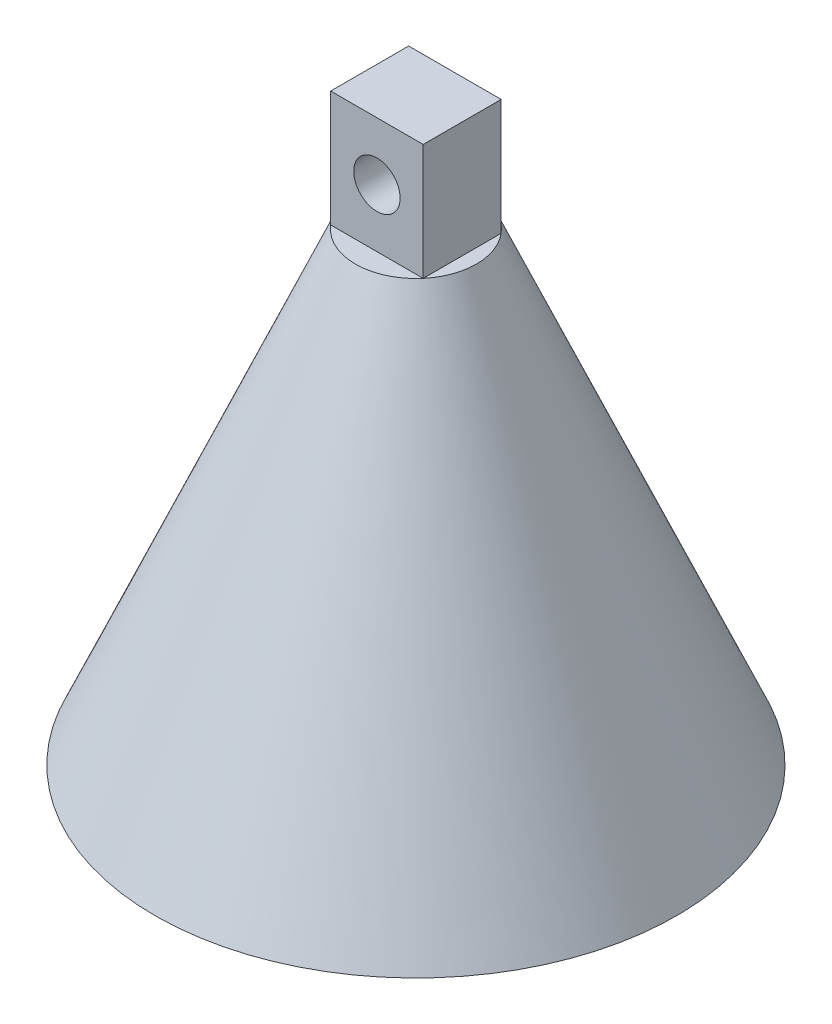
from build123d import *

# Parameters (mm, degrees)
ESQUISSE2_W                  = 7.975229024
ESQUISSE2_H                  = 6.721241558
BOSS_EXTRU_1_DEPTH           = 10
ENL_V_MAT_EXTRU_1_DEPTH      = 14
ENL_V_MAT_EXTRU_1_DEPTH_BACK = 13


with BuildPart() as part:
    # Esquisse1 → Révolution1 (revolve)
    with BuildSketch(Plane.XY):
        Polygon((17.285132647, 40), (19.285132647, 40), (2, 0), (0, 0), align=None)
        Polygon((19.285132647, 40), (18.145144725, 37.361922653), (22.5, 37.361922653), (22.5, 40), align=None)
    revolve(axis=Axis((22.5, 40, 0), (0, -1, 0)))

    # Esquisse2 → Boss.-Extru.1 (add)
    with BuildSketch(Plane(origin=(0, 40, 0), x_dir=(1, 0, 0), z_dir=(0, 1, 0))):
        with Locations((22.5, 0)):
            Rectangle(ESQUISSE2_W, ESQUISSE2_H)
    extrude(amount=BOSS_EXTRU_1_DEPTH)

    # Esquisse3 → Enlèv. mat.-Extru.1 (cut, two sides)
    with BuildSketch(Plane(origin=(0, 0, -3.360620779), x_dir=(-1, 0, 0), z_dir=(0, 0, -1))) as enl_v_mat_extru_1_sk:
        with BuildLine():
            ThreePointArc((-20.5, 45), (-22.5, 47), (-24.5, 45))
            Line((-24.5, 45), (-20.5, 45))
        make_face()
        with BuildLine():
            Line((-20.5, 45), (-24.5, 45))
            ThreePointArc((-24.5, 45), (-22.5, 43), (-20.5, 45))
        make_face()
    extrude(amount=ENL_V_MAT_EXTRU_1_DEPTH, mode=Mode.SUBTRACT)
    extrude(enl_v_mat_extru_1_sk.sketch, amount=-ENL_V_MAT_EXTRU_1_DEPTH_BACK, mode=Mode.SUBTRACT)


solid = part.part
